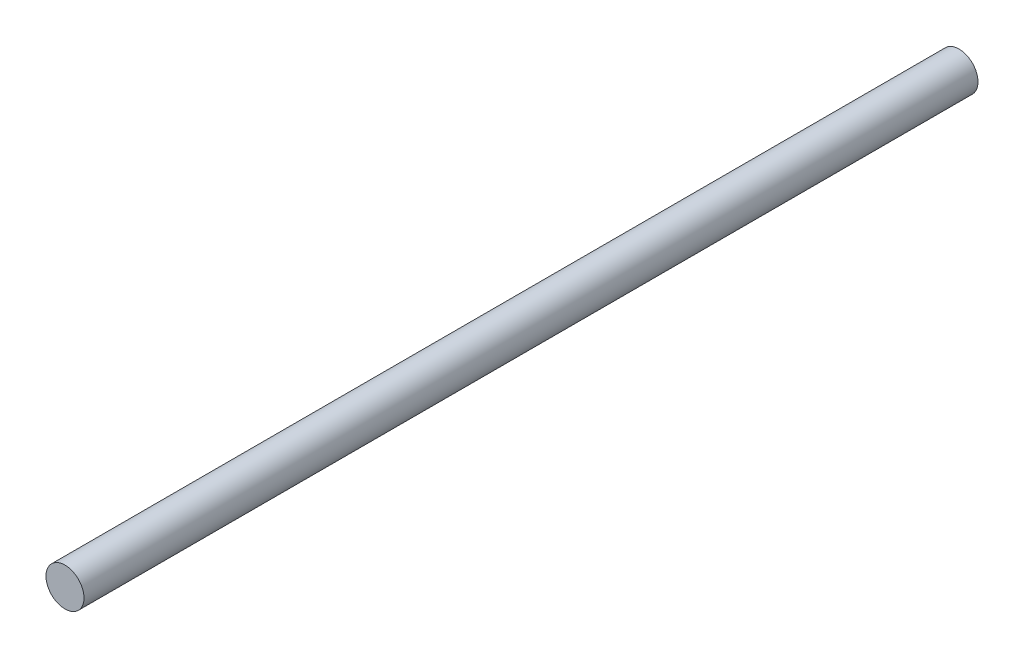
from build123d import *

# Parameters (mm, degrees)
SKETCH_1_R      = 2
EXTRUDE_1_DEPTH = 94


with BuildPart() as part:
    # 草图1 → 凸台-拉伸1 (new body)
    with BuildSketch(Plane.XY):
        Circle(SKETCH_1_R)
    extrude(amount=EXTRUDE_1_DEPTH)


solid = part.part
